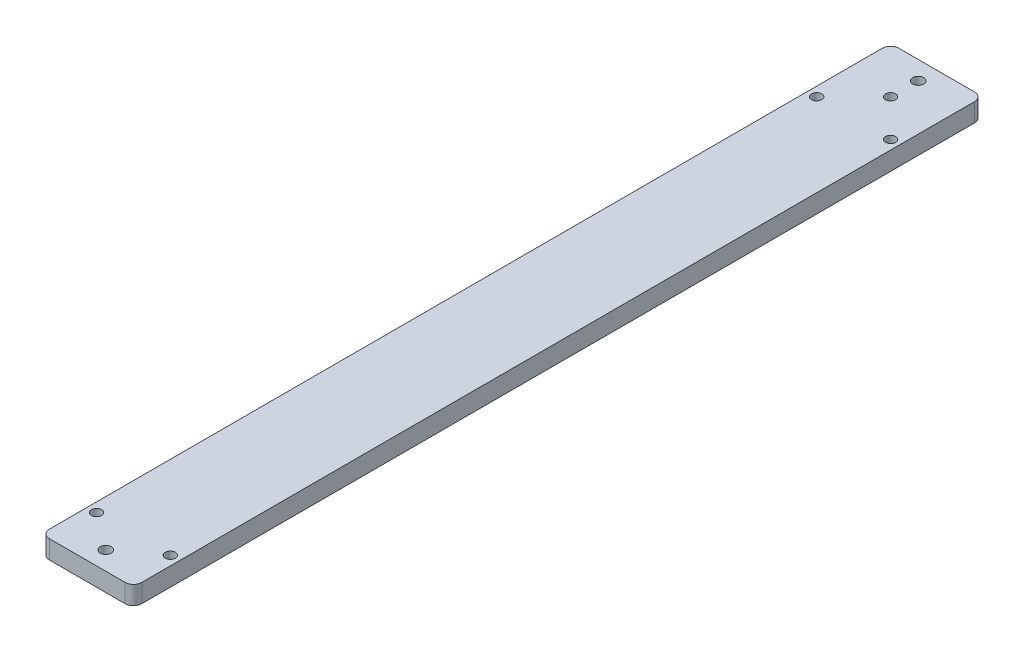
from build123d import *

# Parameters (mm, degrees)
SKETCH1_W           = 50
SKETCH1_H           = 460
BOSS_EXTRUDE1_DEPTH = 10
CUT_EXTRUDE1_REACH  = 12
SKETCH2_R           = 2.75
SKETCH3_R           = 4.5
CUT_EXTRUDE2_DEPTH  = 5.5
CUT_EXTRUDE3_REACH  = 12
SKETCH4_R           = 2.75
SKETCH5_R           = 4.5
CUT_EXTRUDE4_DEPTH  = 5.5
FILLET2_R           = 4.5
CUT_EXTRUDE5_REACH  = 12
SKETCH6_R           = 3


with BuildPart() as part:
    # Sketch1 → Boss-Extrude1 (new body)
    with BuildSketch(Plane.XZ):
        with Locations((12.35332591, 254.692172039)):
            Rectangle(SKETCH1_W, SKETCH1_H)
    extrude(amount=BOSS_EXTRUDE1_DEPTH)

    # Sketch2 → Cut-Extrude1 (cut, up to next)
    with BuildSketch(Plane.XZ.offset(10), mode=Mode.PRIVATE) as cut_extrude1_sk1:
        with Locations((32.35332591, 69.692172039)):
            Circle(SKETCH2_R)
    cut_extrude1_tool1 = extrude(cut_extrude1_sk1.sketch, amount=-CUT_EXTRUDE1_REACH, mode=Mode.PRIVATE) & part.part
    add(cut_extrude1_tool1.solids().sort_by_distance((32.353326, -10, 69.692172))[0], mode=Mode.SUBTRACT)
    # Sketch2 → Cut-Extrude1 (cut, up to next)
    with BuildSketch(Plane.XZ.offset(10), mode=Mode.PRIVATE) as cut_extrude1_sk2:
        with Locations((-7.64667409, 69.692172039)):
            Circle(SKETCH2_R)
    cut_extrude1_tool2 = extrude(cut_extrude1_sk2.sketch, amount=-CUT_EXTRUDE1_REACH, mode=Mode.PRIVATE) & part.part
    add(cut_extrude1_tool2.solids().sort_by_distance((-7.646674, -10, 69.692172))[0], mode=Mode.SUBTRACT)
    # Sketch2 → Cut-Extrude1 (cut, up to next)
    with BuildSketch(Plane.XZ.offset(10), mode=Mode.PRIVATE) as cut_extrude1_sk3:
        with Locations((12.35332591, 49.692172039)):
            Circle(SKETCH2_R)
    cut_extrude1_tool3 = extrude(cut_extrude1_sk3.sketch, amount=-CUT_EXTRUDE1_REACH, mode=Mode.PRIVATE) & part.part
    add(cut_extrude1_tool3.solids().sort_by_distance((12.353326, -10, 49.692172))[0], mode=Mode.SUBTRACT)

    # Sketch3 → Cut-Extrude2 (cut)
    with BuildSketch(Plane.XZ.offset(10)):
        with Locations((-7.64667409, 69.692172039)):
            Circle(SKETCH3_R)
        with Locations((32.35332591, 69.692172039)):
            Circle(SKETCH3_R)
        with Locations((12.35332591, 49.692172039)):
            Circle(SKETCH3_R)
    extrude(amount=-CUT_EXTRUDE2_DEPTH, mode=Mode.SUBTRACT)

    # Sketch4 → Cut-Extrude3 (cut, up to next)
    with BuildSketch(Plane.XZ.offset(10), mode=Mode.PRIVATE) as cut_extrude3_sk1:
        with Locations((-7.64667409, 459.692172039)):
            Circle(SKETCH4_R)
    cut_extrude3_tool1 = extrude(cut_extrude3_sk1.sketch, amount=-CUT_EXTRUDE3_REACH, mode=Mode.PRIVATE) & part.part
    add(cut_extrude3_tool1.solids().sort_by_distance((-7.646674, -10, 459.692172))[0], mode=Mode.SUBTRACT)
    # Sketch4 → Cut-Extrude3 (cut, up to next)
    with BuildSketch(Plane.XZ.offset(10), mode=Mode.PRIVATE) as cut_extrude3_sk2:
        with Locations((32.35332591, 459.692172039)):
            Circle(SKETCH4_R)
    cut_extrude3_tool2 = extrude(cut_extrude3_sk2.sketch, amount=-CUT_EXTRUDE3_REACH, mode=Mode.PRIVATE) & part.part
    add(cut_extrude3_tool2.solids().sort_by_distance((32.353326, -10, 459.692172))[0], mode=Mode.SUBTRACT)

    # Sketch5 → Cut-Extrude4 (cut)
    with BuildSketch(Plane.XZ.offset(10)):
        with Locations((-7.64667409, 459.692172039)):
            Circle(SKETCH5_R)
        with Locations((32.35332591, 459.692172039)):
            Circle(SKETCH5_R)
    extrude(amount=-CUT_EXTRUDE4_DEPTH, mode=Mode.SUBTRACT)

    # Fillet2
    fillet2_edges = [part.edges().sort_by_distance(p)[0] for p in [
        (37.35332591, -5, 24.692172039),
        (-12.64667409, -5, 24.692172039),
        (-12.64667409, -5, 484.692172039),
        (37.35332591, -5, 484.692172039),
    ]]
    fillet(fillet2_edges, radius=FILLET2_R)

    # Sketch6 → Cut-Extrude5 (cut, up to next)
    with BuildSketch(Plane(origin=(0, 0, 0), x_dir=(-1, 0, 0), z_dir=(0, 1, 0)), mode=Mode.PRIVATE) as cut_extrude5_sk1:
        with Locations((-12.35332591, 474.692172039)):
            Circle(SKETCH6_R)
    cut_extrude5_tool1 = extrude(cut_extrude5_sk1.sketch, amount=-CUT_EXTRUDE5_REACH, mode=Mode.PRIVATE) & part.part
    add(cut_extrude5_tool1.solids().sort_by_distance((12.353326, 0, 474.692172))[0], mode=Mode.SUBTRACT)
    # Sketch6 → Cut-Extrude5 (cut, up to next)
    with BuildSketch(Plane(origin=(0, 0, 0), x_dir=(-1, 0, 0), z_dir=(0, 1, 0)), mode=Mode.PRIVATE) as cut_extrude5_sk2:
        with Locations((-12.35332591, 34.692172039)):
            Circle(SKETCH6_R)
    cut_extrude5_tool2 = extrude(cut_extrude5_sk2.sketch, amount=-CUT_EXTRUDE5_REACH, mode=Mode.PRIVATE) & part.part
    add(cut_extrude5_tool2.solids().sort_by_distance((12.353326, 0, 34.692172))[0], mode=Mode.SUBTRACT)


solid = part.part
